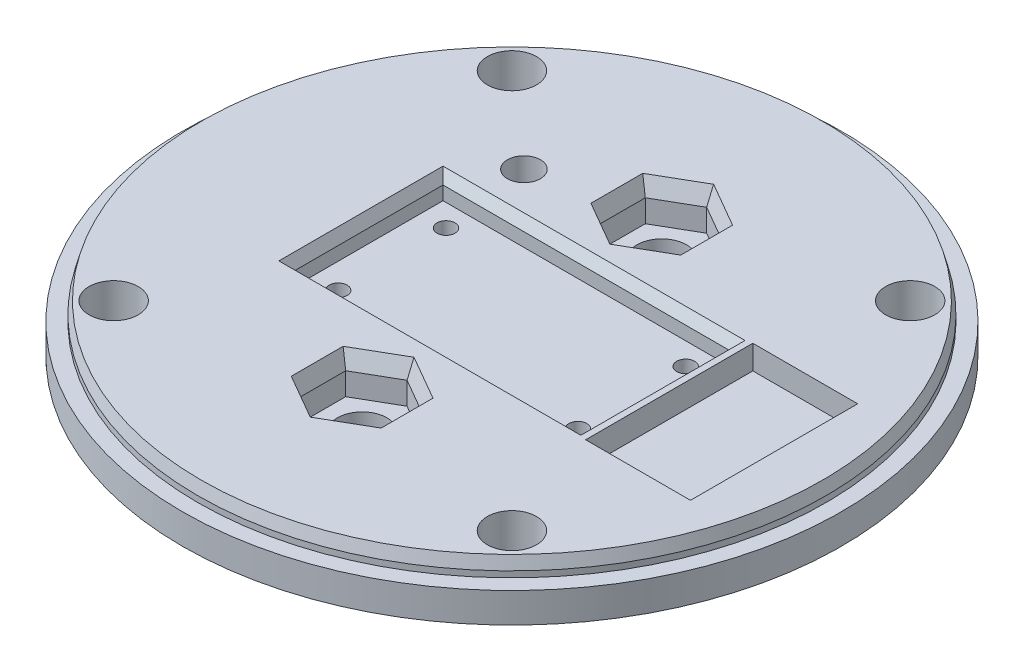
from build123d import *

# Parameters (mm, degrees)
SKETCH_1_R          = 55
EXTRUDE_1_DEPTH     = 5
SKETCH_2_R          = 52.4
EXTRUDE_2_DEPTH     = 3
SKETCH_3_W          = 35
SKETCH_3_H          = 30
EXTRUDE_3_DEPTH     = 25
SKETCH_5_R          = 4.1
CUT_EXTRUDE_2_DEPTH = 9
SKETCH_6_R          = 2.75
CUT_EXTRUDE_3_DEPTH = 34
SKETCH2_W           = 20.25
SKETCH2_H           = 10.35
CUT_EXTRUDE1_DEPTH  = 73.5
SKETCH3_W           = 17.5
SKETCH3_H           = 27.9
SKETCH3_W_2         = 48.4
SKETCH3_H_2         = 25.4
CUT_EXTRUDE2_DEPTH  = 4
CHAMFER1_SIZE       = 2
CHAMFER1_SIZE2      = 0.535898385
SKETCH4_W           = 35
SKETCH4_H           = 30
CUT_EXTRUDE3_DEPTH  = 12.5
BOSS_EXTRUDE2_START = -2
SKETCH5_W           = 20
SKETCH5_H           = 70
BOSS_EXTRUDE2_DEPTH = 5.325
SKETCH6_R           = 4.15
CUT_EXTRUDE4_DEPTH  = 14.325
CUT_EXTRUDE5_DEPTH  = 6.5
CHAMFER2_SIZE       = 1
CHAMFER2_SIZE2      = 2.747477419
SKETCH8_R           = 1.5
CUT_EXTRUDE6_DEPTH  = 17.5
CHAMFER3_SIZE       = 1
CHAMFER3_SIZE2      = 1.732050808


with BuildPart() as part:
    # Эскиз1 → Бобышка-Вытянуть1 (new body)
    with BuildSketch(Plane(origin=(0, 0, 0), x_dir=(1, 0, 0), z_dir=(0, 1, 0))):
        with Locations(Location((0, 0, 0), (0, 0, 270))):  # turned: the seam where the file's is
            Circle(SKETCH_1_R)
    extrude(amount=EXTRUDE_1_DEPTH)

    # Эскиз2 → Бобышка-Вытянуть2 (add)
    with BuildSketch(Plane(origin=(0, 5, 0), x_dir=(1, 0, 0), z_dir=(0, 1, 0))):
        with Locations(Location((0, 0, 0), (0, 0, 270))):  # turned: the seam where the file's is
            Circle(SKETCH_2_R)
    extrude(amount=EXTRUDE_2_DEPTH)

    # Эскиз3 → Бобышка-Вытянуть3 (add)
    with BuildSketch(Plane.XZ):
        Rectangle(SKETCH_3_W, SKETCH_3_H)
    extrude(amount=EXTRUDE_3_DEPTH)

    # Эскиз5 → Вырез-Вытянуть2 (cut, through all)
    with BuildSketch(Plane.XZ):
        with Locations(Location((33.234018716, -33.234018716, 0), (0, 0, 270))):  # turned: the seam where the file's is
            Circle(SKETCH_5_R)
        with Locations(Location((-33.234018716, -33.234018716, 0), (0, 0, 270))):  # turned: the seam where the file's is
            Circle(SKETCH_5_R)
        with Locations(Location((-33.234018716, 33.234018716, 0), (0, 0, 270))):  # turned: the seam where the file's is
            Circle(SKETCH_5_R)
        with Locations(Location((33.234018716, 33.234018716, 0), (0, 0, 270))):  # turned: the seam where the file's is
            Circle(SKETCH_5_R)
    extrude(amount=-CUT_EXTRUDE_2_DEPTH, mode=Mode.SUBTRACT)

    # Эскиз6 → Вырез-Вытянуть3 (cut, through all)
    with BuildSketch(Plane(origin=(0, 8, 0), x_dir=(1, 0, 0), z_dir=(0, 1, 0))):
        with Locations(Location((-18, 20, 0), (0, 0, 270))):  # turned: the seam where the file's is
            Circle(SKETCH_6_R)
    extrude(amount=-CUT_EXTRUDE_3_DEPTH, mode=Mode.SUBTRACT)

    # Sketch2 → Cut-Extrude1 (cut, through all)
    with BuildSketch(Plane.ZY.offset(17.5)):
        with Locations((0, -12.5)):
            Rectangle(SKETCH2_W, SKETCH2_H)
    extrude(amount=-CUT_EXTRUDE1_DEPTH, mode=Mode.SUBTRACT)

    # Sketch3 → Cut-Extrude2 (cut)
    with BuildSketch(Plane(origin=(0, 8, 0), x_dir=(1, 0, 0), z_dir=(0, 1, 0))):
        with Locations((35, 0)):
            Rectangle(SKETCH3_W, SKETCH3_H)
        Rectangle(SKETCH3_W_2, SKETCH3_H_2)
    extrude(amount=-CUT_EXTRUDE2_DEPTH, mode=Mode.SUBTRACT)

    # Chamfer1
    chamfer1_edges = [part.edges().sort_by_distance(p)[0] for p in [
        (0, 8, -52.4),
    ]]
    chamfer1_side = [part.faces().sort_by_distance(p)[0] for p in [
        (0, 6.5, -52.4),
    ]]
    chamfer(chamfer1_edges, length=CHAMFER1_SIZE, length2=CHAMFER1_SIZE2, reference=chamfer1_side[0])

    # Sketch4 → Cut-Extrude3 (cut)
    with BuildSketch(Plane.XZ.offset(25)):
        Rectangle(SKETCH4_W, SKETCH4_H)
    extrude(amount=-CUT_EXTRUDE3_DEPTH, mode=Mode.SUBTRACT)

    # Sketch5 → Boss-Extrude2 (add)
    with BuildSketch(Plane.XZ.offset(7.325).offset(BOSS_EXTRUDE2_START)):
        Rectangle(SKETCH5_W, SKETCH5_H)
    extrude(amount=-BOSS_EXTRUDE2_DEPTH)

    # Sketch6 → Cut-Extrude4 (cut, through all)
    with BuildSketch(Plane.XZ.offset(5.325)):
        with Locations(Location((0, 25, 0), (0, 0, 270))):  # turned: the seam where the file's is
            Circle(SKETCH6_R)
        with Locations(Location((0, -25, 0), (0, 0, 270))):  # turned: the seam where the file's is
            Circle(SKETCH6_R)
    extrude(amount=-CUT_EXTRUDE4_DEPTH, mode=Mode.SUBTRACT)

    # Sketch7 → Cut-Extrude5 (cut)
    with BuildSketch(Plane(origin=(0, 8, 0), x_dir=(1, 0, 0), z_dir=(0, 1, 0))):
        Polygon((0, -32.5), (6.495190528, -28.75), (6.495190528, -21.25), (0, -17.5), (-6.495190528, -21.25), (-6.495190528, -28.75), align=None)
        Polygon((0, 17.5), (6.495190528, 21.25), (6.495190528, 28.75), (0, 32.5), (-6.495190528, 28.75), (-6.495190528, 21.25), align=None)
    extrude(amount=-CUT_EXTRUDE5_DEPTH, mode=Mode.SUBTRACT)

    # Chamfer2
    chamfer2_edges = [part.edges().sort_by_distance(p)[0] for p in [
        (-3.247595264, 8, 30.625),
        (3.247595264, 8, 30.625),
        (6.495190528, 8, 25),
        (3.247595264, 8, 19.375),
        (-3.247595264, 8, 19.375),
        (-6.495190528, 8, 25),
        (-3.247595264, 8, -19.375),
        (3.247595264, 8, -19.375),
        (6.495190528, 8, -25),
        (3.247595264, 8, -30.625),
        (-3.247595264, 8, -30.625),
        (-6.495190528, 8, -25),
    ]]
    chamfer2_side = [part.faces().sort_by_distance(p)[0] for p in [
        (0, 8, -50.397163297),
    ]]
    chamfer(chamfer2_edges, length=CHAMFER2_SIZE, length2=CHAMFER2_SIZE2, reference=chamfer2_side[0])

    # Sketch8 → Cut-Extrude6 (cut, through all)
    with BuildSketch(Plane(origin=(0, 4, 0), x_dir=(1, 0, 0), z_dir=(0, 1, 0))):
        with Locations(Location((20, 9, 0), (0, 0, 270))):  # turned: the seam where the file's is
            Circle(SKETCH8_R)
        with Locations(Location((20, -9, 0), (0, 0, 270))):  # turned: the seam where the file's is
            Circle(SKETCH8_R)
        with Locations(Location((-20, 9, 0), (0, 0, 270))):  # turned: the seam where the file's is
            Circle(SKETCH8_R)
        with Locations(Location((-20, -9, 0), (0, 0, 270))):  # turned: the seam where the file's is
            Circle(SKETCH8_R)
    extrude(amount=-CUT_EXTRUDE6_DEPTH, mode=Mode.SUBTRACT)

    # Chamfer3
    chamfer3_edges = [part.edges().sort_by_distance(p)[0] for p in [
        (24.2, 8, 0),
        (0, 8, -12.7),
        (-24.2, 8, 0),
        (0, 8, 12.7),
    ]]
    chamfer3_side = [part.faces().sort_by_distance(p)[0] for p in [
        (-4.481064423, 8, 32.761431253),
    ]]
    chamfer(chamfer3_edges, length=CHAMFER3_SIZE, length2=CHAMFER3_SIZE2, reference=chamfer3_side[0])


solid = part.part
